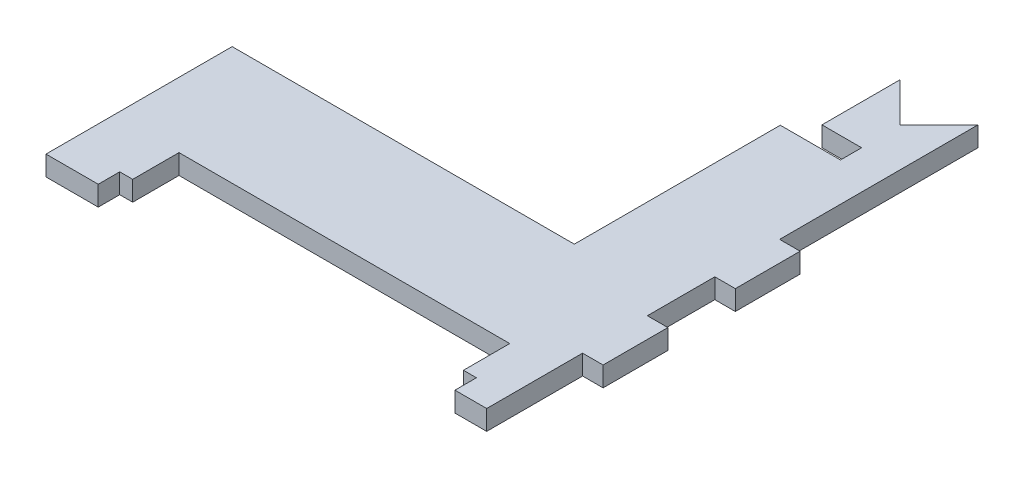
from build123d import *

# Parameters (mm, degrees)
BOSS_EXTRUDE1_DEPTH = 3
SKETCH6_W           = 3.2
SKETCH6_H           = 30.2
SKETCH6_H_2         = 10.2
CUT_EXTRUDE3_DEPTH  = 4


with BuildPart() as part:
    # Sketch1 → Boss-Extrude1 (new body)
    with BuildSketch(Plane(origin=(0, 0, 0), x_dir=(1, 0, 0), z_dir=(0, 1, 0))):
        Polygon((-34.872217102, 0), (34.872217102, 0), (34.872217102, 75), (31.872217102, 75), (25.872217102, 69), (19.872217102, 75), (16.872217102, 75), (16.872217102, 28.75), (-34.872217102, 28.75), align=None)
    extrude(amount=BOSS_EXTRUDE1_DEPTH)

    # Sketch6 → Cut-Extrude3 (cut, through all)
    with BuildSketch(Plane(origin=(0, 0, 0), x_dir=(1, 0, 0), z_dir=(0, 1, 0))):
        with Locations((33.372217102, 60)):
            Rectangle(SKETCH6_W, SKETCH6_H)
        with Locations((33.372217102, 30)):
            Rectangle(SKETCH6_W, SKETCH6_H_2)
        Polygon((25.972217102, 63.1), (19.972217102, 63.1), (19.972217102, 75.1), (16.772217102, 75.1), (16.772217102, 59.9), (25.972217102, 59.9), align=None)
        Polygon((34.972217102, -0.1), (34.972217102, 15.1), (31.772217102, 15.1), (31.772217102, 0.6), (26.972217102, 0.6), (26.972217102, 3.85), (25.008726501, 3.85), (25.008726501, 10.85), (-25.008726501, 10.85), (-25.008726501, 3.85), (-26.972217102, 3.85), (-26.972217102, 0.6), (-34.972217102, 0.6), (-34.972217102, -0.1), align=None)
    extrude(amount=CUT_EXTRUDE3_DEPTH, mode=Mode.SUBTRACT)


solid = part.part
